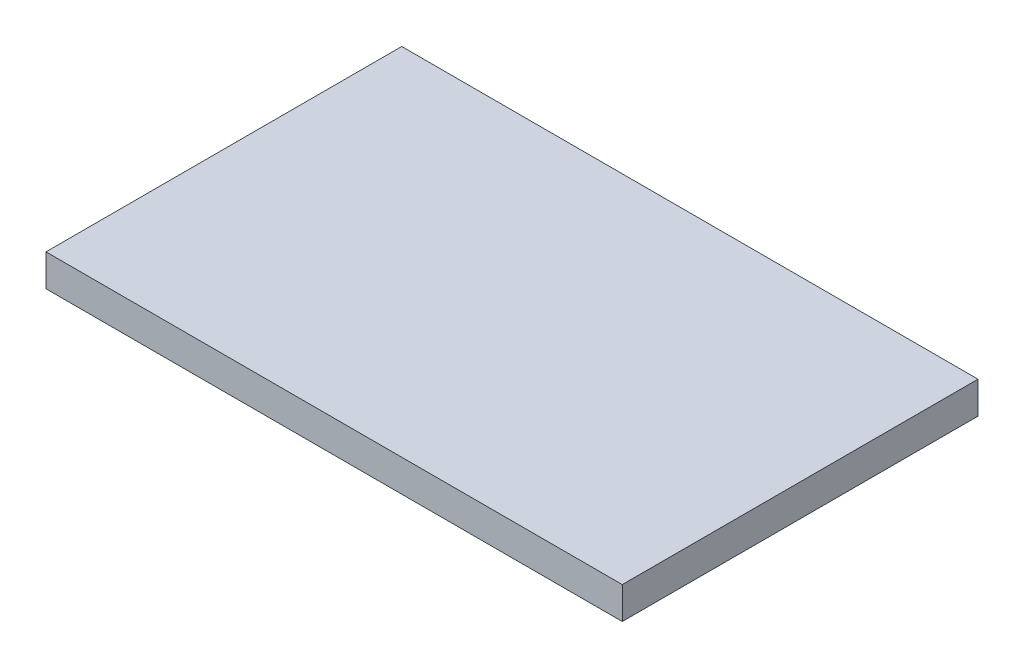
from build123d import *

# Parameters (mm, degrees)
SKETCH_1_W      = 81
SKETCH_1_H      = 50
EXTRUDE_1_DEPTH = 4.5


with BuildPart() as part:
    # 草圖1 → 填料-伸長1 (new body)
    with BuildSketch(Plane(origin=(0, 0, 0), x_dir=(1, 0, 0), z_dir=(0, 1, 0))):
        Rectangle(SKETCH_1_W, SKETCH_1_H)
    extrude(amount=EXTRUDE_1_DEPTH)


solid = part.part
